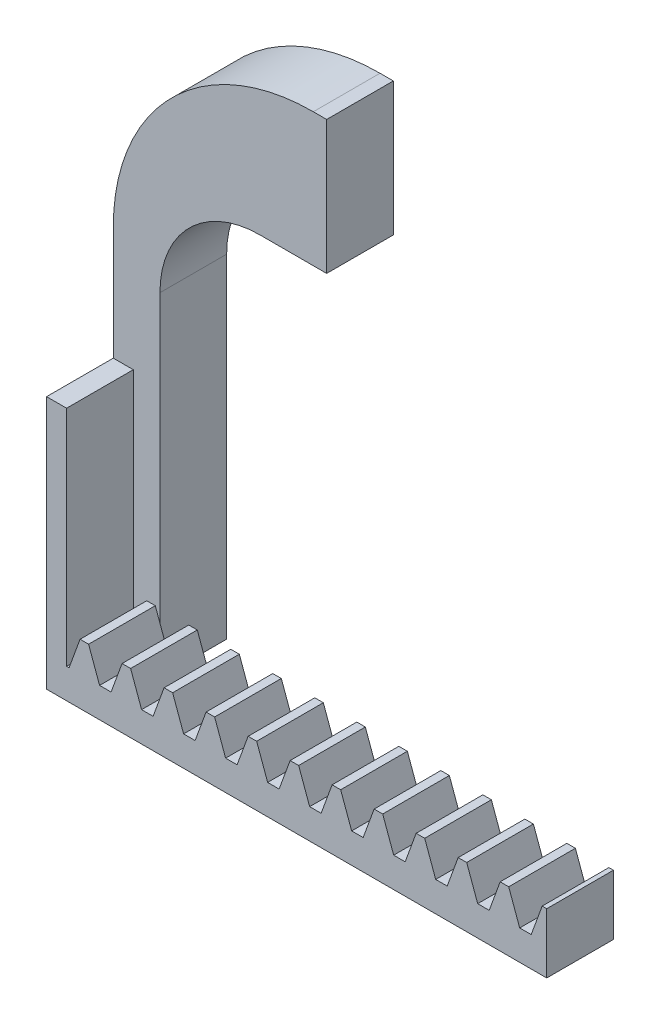
from build123d import *

# Parameters (mm, degrees)
BOSS_EXTRUDE1_DEPTH             = 10
SKIZZE2_W                       = 75
SKIZZE2_H                       = 9
AUFSATZ_LINEAR_AUSTRAGEN1_DEPTH = 10
SCHNITT_LINEAR_AUSTRAGEN2_DEPTH = 10
AUFSATZ_LINEAR_AUSTRAGEN2_DEPTH = 3


with BuildPart() as part:
    # Sketch1 → Boss-Extrude1 (new body)
    with BuildSketch(Plane.XY):
        with BuildLine():
            Line((7, 0), (0, 0))
            Line((0, 0), (0, 47.7))
            Line((0, 47.7), (0, 55))
            ThreePointArc((0, 55), (8.786796564, 76.213203436), (30, 85))
            Line((30, 85), (32, 85))
            Line((32, 85), (32, 65))
            Line((32, 65), (22, 65))
            ThreePointArc((22, 65), (11.393398282, 60.606601718), (7, 50))
            Line((7, 50), (7, 0))
        make_face()
    extrude(amount=BOSS_EXTRUDE1_DEPTH)

    # Skizze2 → Aufsatz-Linear austragen1 (add)
    with BuildSketch(Plane.XY.offset(10)):
        with Locations((37.5, 4.5)):
            Rectangle(SKIZZE2_W, SKIZZE2_H)
    extrude(amount=AUFSATZ_LINEAR_AUSTRAGEN1_DEPTH)

    # Skizze3 → Schnitt-Linear austragen2 (cut)
    with BuildSketch(Plane.XY.offset(20)):
        Polygon((3.370852377, 4.4746), (1.647110898, 4.4746), (0, 9), (5.017963275, 9), align=None)
        Polygon((9.670852377, 4.4746), (7.947110898, 4.4746), (6.3, 9), (11.317963275, 9), align=None)
        Polygon((15.970852377, 4.4746), (14.247110898, 4.4746), (12.6, 9), (17.617963275, 9), align=None)
        Polygon((22.270852377, 4.4746), (20.547110898, 4.4746), (18.9, 9), (23.917963275, 9), align=None)
        Polygon((28.570852377, 4.4746), (26.847110898, 4.4746), (25.2, 9), (30.217963275, 9), align=None)
        Polygon((34.870852377, 4.4746), (33.147110898, 4.4746), (31.5, 9), (36.517963275, 9), align=None)
        Polygon((41.170852377, 4.4746), (39.447110898, 4.4746), (37.8, 9), (42.817963275, 9), align=None)
        Polygon((47.470852377, 4.4746), (45.747110898, 4.4746), (44.1, 9), (49.117963275, 9), align=None)
        Polygon((53.770852377, 4.4746), (52.047110898, 4.4746), (50.4, 9), (55.417963275, 9), align=None)
        Polygon((60.070852377, 4.4746), (58.347110898, 4.4746), (56.7, 9), (61.717963275, 9), align=None)
        Polygon((66.370852377, 4.4746), (64.647110898, 4.4746), (63, 9), (68.017963275, 9), align=None)
        Polygon((72.670852377, 4.4746), (70.947110898, 4.4746), (69.3, 9), (74.317963275, 9), align=None)
    extrude(amount=-SCHNITT_LINEAR_AUSTRAGEN2_DEPTH, mode=Mode.SUBTRACT)

    # Skizze4 → Aufsatz-Linear austragen2 (add)
    with BuildSketch(Plane.ZY):
        Polygon((20, 0), (0, 0), (0, 48), (10, 48), (10, 38), (20, 38), align=None)
    extrude(amount=-AUFSATZ_LINEAR_AUSTRAGEN2_DEPTH)


solid = part.part
